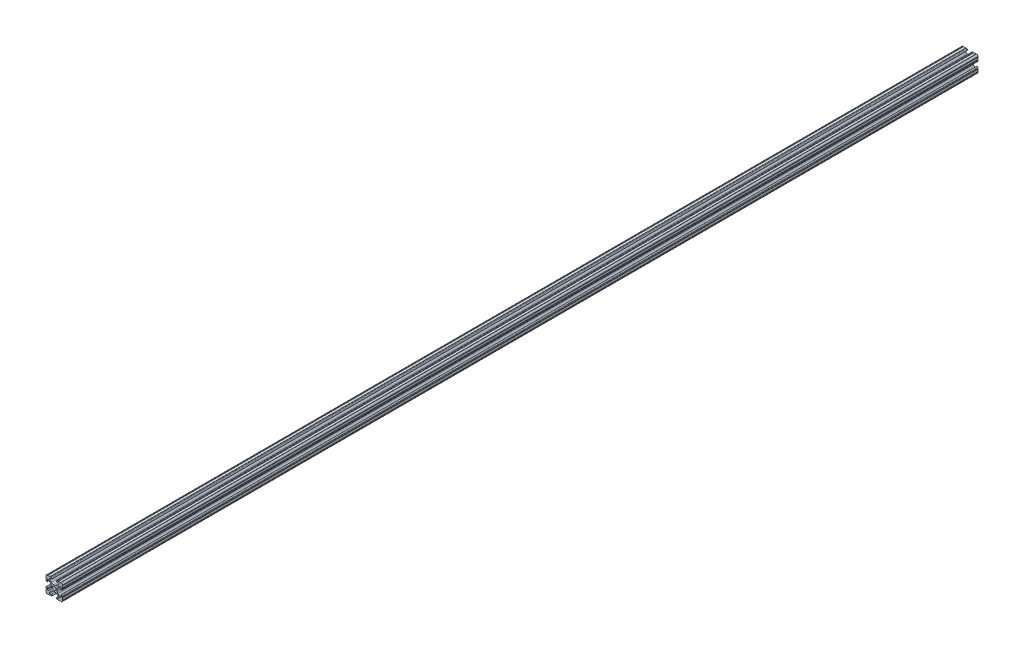
from build123d import *

# Parameters (mm, degrees)
SKETCH3_R      = 2.6035
EXTRUDE1_DEPTH = 711.2


with BuildPart() as part:
    # Sketch3 → Extrude1 (new body, symmetric)
    with BuildSketch(Plane.XY):
        with BuildLine():
            Line((-1.115277175, 4.5085), (1.115277175, 4.5085))
            ThreePointArc((1.115277175, 4.5085), (2.806584872, 4.844922018), (4.240406305, 5.80297087))
            Line((4.240406305, 5.80297087), (7.148423664, 8.710988229))
            ThreePointArc((7.148423664, 8.710988229), (7.349906316, 9.772227925), (6.436353897, 10.348636575))
            Line((6.436353897, 10.348636575), (4.381960454, 10.276895575))
            ThreePointArc((4.381960454, 10.276895575), (3.239173075, 11.342562046), (4.304839546, 12.485349424))
            Line((4.304839546, 12.485349424), (5.728246175, 12.535055879))
            ThreePointArc((5.728246175, 12.535055879), (6.054756855, 12.230579745), (6.35923299, 12.557090424))
            Line((6.35923299, 12.557090424), (9.782092278, 12.676619304))
            ThreePointArc((9.782092278, 12.676619304), (10.108602958, 12.37214317), (10.413079092, 12.69865385))
            ThreePointArc((10.413079092, 12.69865385), (12.052764565, 12.052764565), (12.69865385, 10.413079092))
            ThreePointArc((12.69865385, 10.413079092), (12.37214317, 10.108602958), (12.676619304, 9.782092278))
            Line((12.676619304, 9.782092278), (12.557090424, 6.35923299))
            ThreePointArc((12.557090424, 6.35923299), (12.230579745, 6.054756855), (12.535055879, 5.728246175))
            Line((12.535055879, 5.728246175), (12.485349424, 4.304839546))
            ThreePointArc((12.485349424, 4.304839546), (11.342562046, 3.239173075), (10.276895575, 4.381960454))
            Line((10.276895575, 4.381960454), (10.348636575, 6.436353897))
            ThreePointArc((10.348636575, 6.436353897), (9.772227925, 7.349906316), (8.710988229, 7.148423664))
            Line((8.710988229, 7.148423664), (5.80297087, 4.240406305))
            ThreePointArc((5.80297087, 4.240406305), (4.844922018, 2.806584872), (4.5085, 1.115277175))
            Line((4.5085, 1.115277175), (4.5085, -1.115277175))
            ThreePointArc((4.5085, -1.115277175), (4.844922018, -2.806584872), (5.80297087, -4.240406305))
            Line((5.80297087, -4.240406305), (8.710988229, -7.148423664))
            ThreePointArc((8.710988229, -7.148423664), (9.772227925, -7.349906316), (10.348636575, -6.436353897))
            Line((10.348636575, -6.436353897), (10.276895575, -4.381960454))
            ThreePointArc((10.276895575, -4.381960454), (11.342562046, -3.239173075), (12.485349424, -4.304839546))
            Line((12.485349424, -4.304839546), (12.535055879, -5.728246175))
            ThreePointArc((12.535055879, -5.728246175), (12.230579745, -6.054756855), (12.557090424, -6.35923299))
            Line((12.557090424, -6.35923299), (12.676619304, -9.782092278))
            ThreePointArc((12.676619304, -9.782092278), (12.37214317, -10.108602958), (12.69865385, -10.413079092))
            ThreePointArc((12.69865385, -10.413079092), (12.052764565, -12.052764565), (10.413079092, -12.69865385))
            ThreePointArc((10.413079092, -12.69865385), (10.108602958, -12.37214317), (9.782092278, -12.676619304))
            Line((9.782092278, -12.676619304), (6.35923299, -12.557090424))
            ThreePointArc((6.35923299, -12.557090424), (6.054756855, -12.230579745), (5.728246175, -12.535055879))
            Line((5.728246175, -12.535055879), (4.304839546, -12.485349424))
            ThreePointArc((4.304839546, -12.485349424), (3.239173075, -11.342562046), (4.381960454, -10.276895575))
            Line((4.381960454, -10.276895575), (6.436353897, -10.348636575))
            ThreePointArc((6.436353897, -10.348636575), (7.349906316, -9.772227925), (7.148423664, -8.710988229))
            Line((7.148423664, -8.710988229), (4.240406305, -5.80297087))
            ThreePointArc((4.240406305, -5.80297087), (2.806584872, -4.844922018), (1.115277175, -4.5085))
            Line((1.115277175, -4.5085), (-1.115277175, -4.5085))
            ThreePointArc((-1.115277175, -4.5085), (-2.806584872, -4.844922018), (-4.240406305, -5.80297087))
            Line((-4.240406305, -5.80297087), (-7.148423664, -8.710988229))
            ThreePointArc((-7.148423664, -8.710988229), (-7.349906316, -9.772227925), (-6.436353897, -10.348636575))
            Line((-6.436353897, -10.348636575), (-4.381960454, -10.276895575))
            ThreePointArc((-4.381960454, -10.276895575), (-3.239173075, -11.342562046), (-4.304839546, -12.485349424))
            Line((-4.304839546, -12.485349424), (-5.728246175, -12.535055879))
            ThreePointArc((-5.728246175, -12.535055879), (-6.054756855, -12.230579745), (-6.35923299, -12.557090424))
            Line((-6.35923299, -12.557090424), (-9.782092278, -12.676619304))
            ThreePointArc((-9.782092278, -12.676619304), (-10.108602958, -12.37214317), (-10.413079092, -12.69865385))
            ThreePointArc((-10.413079092, -12.69865385), (-12.052764565, -12.052764565), (-12.69865385, -10.413079092))
            ThreePointArc((-12.69865385, -10.413079092), (-12.37214317, -10.108602958), (-12.676619304, -9.782092278))
            Line((-12.676619304, -9.782092278), (-12.557090424, -6.35923299))
            ThreePointArc((-12.557090424, -6.35923299), (-12.230579745, -6.054756855), (-12.535055879, -5.728246175))
            Line((-12.535055879, -5.728246175), (-12.485349424, -4.304839546))
            ThreePointArc((-12.485349424, -4.304839546), (-11.342562046, -3.239173075), (-10.276895575, -4.381960454))
            Line((-10.276895575, -4.381960454), (-10.348636575, -6.436353897))
            ThreePointArc((-10.348636575, -6.436353897), (-9.772227925, -7.349906316), (-8.710988229, -7.148423664))
            Line((-8.710988229, -7.148423664), (-5.80297087, -4.240406305))
            ThreePointArc((-5.80297087, -4.240406305), (-4.844922018, -2.806584872), (-4.5085, -1.115277175))
            Line((-4.5085, -1.115277175), (-4.5085, 1.115277175))
            ThreePointArc((-4.5085, 1.115277175), (-4.844922018, 2.806584872), (-5.80297087, 4.240406305))
            Line((-5.80297087, 4.240406305), (-8.710988229, 7.148423664))
            ThreePointArc((-8.710988229, 7.148423664), (-9.772227925, 7.349906316), (-10.348636575, 6.436353897))
            Line((-10.348636575, 6.436353897), (-10.276895575, 4.381960454))
            ThreePointArc((-10.276895575, 4.381960454), (-11.342562046, 3.239173075), (-12.485349424, 4.304839546))
            Line((-12.485349424, 4.304839546), (-12.535055879, 5.728246175))
            ThreePointArc((-12.535055879, 5.728246175), (-12.230579745, 6.054756855), (-12.557090424, 6.35923299))
            Line((-12.557090424, 6.35923299), (-12.676619304, 9.782092278))
            ThreePointArc((-12.676619304, 9.782092278), (-12.37214317, 10.108602958), (-12.69865385, 10.413079092))
            ThreePointArc((-12.69865385, 10.413079092), (-12.052764565, 12.052764565), (-10.413079092, 12.69865385))
            ThreePointArc((-10.413079092, 12.69865385), (-10.108602958, 12.37214317), (-9.782092278, 12.676619304))
            Line((-9.782092278, 12.676619304), (-6.35923299, 12.557090424))
            ThreePointArc((-6.35923299, 12.557090424), (-6.054756855, 12.230579745), (-5.728246175, 12.535055879))
            Line((-5.728246175, 12.535055879), (-4.304839546, 12.485349424))
            ThreePointArc((-4.304839546, 12.485349424), (-3.239173075, 11.342562046), (-4.381960454, 10.276895575))
            Line((-4.381960454, 10.276895575), (-6.436353897, 10.348636575))
            ThreePointArc((-6.436353897, 10.348636575), (-7.349906316, 9.772227925), (-7.148423664, 8.710988229))
            Line((-7.148423664, 8.710988229), (-4.240406305, 5.80297087))
            ThreePointArc((-4.240406305, 5.80297087), (-2.806584872, 4.844922018), (-1.115277175, 4.5085))
        make_face()
        Circle(SKETCH3_R, mode=Mode.SUBTRACT)
    extrude(amount=EXTRUDE1_DEPTH, both=True)


solid = part.part
